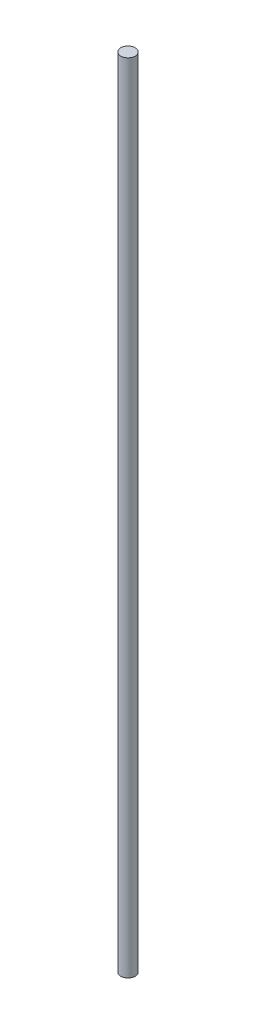
from build123d import *

# Parameters (mm, degrees)
SKETCH1_R           = 6
BOSS_EXTRUDE1_DEPTH = 660


with BuildPart() as part:
    # Sketch1 → Boss-Extrude1 (new body)
    with BuildSketch(Plane(origin=(0, 0, 0), x_dir=(1, 0, 0), z_dir=(0, 1, 0))):
        Circle(SKETCH1_R)
    extrude(amount=BOSS_EXTRUDE1_DEPTH)


solid = part.part
